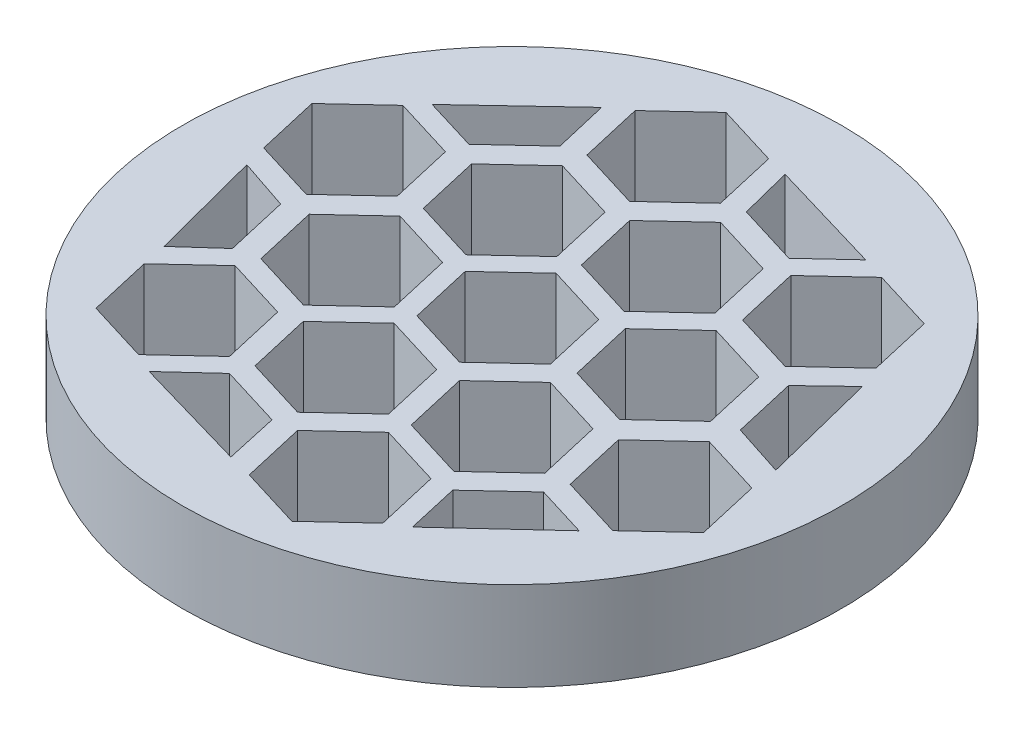
from build123d import *

# Parameters (mm, degrees)
SKIZZE1_R                       = 7.4
AUFSATZ_LINEAR_AUSTRAGEN2_DEPTH = 2
SCHNITT_LINEAR_AUSTRAGEN2_DEPTH = 2


with BuildPart() as part:
    # Skizze1 → Aufsatz-Linear austragen2 (new body)
    with BuildSketch(Plane(origin=(0, 0, 0), x_dir=(1, 0, 0), z_dir=(0, 1, 0))):
        Circle(SKIZZE1_R)
    extrude(amount=AUFSATZ_LINEAR_AUSTRAGEN2_DEPTH)

    # Skizze3 → Schnitt-Linear austragen2 (cut)
    with BuildSketch(Plane.XZ):
        Polygon((3.110355434, 1.292281092), (3.433750851, 2.698961133), (2.377227909, 3.6823698), (0.99730955, 3.259098426), (0.673914133, 1.852418385), (1.730437075, 0.869009718), align=None)
        Polygon((1.051482334, -0.894820995), (1.374877751, 0.511859046), (0.318354809, 1.495267713), (-1.06156355, 1.071996339), (-1.384958967, -0.334683702), (-0.328436025, -1.318092369), align=None)
        Polygon((3.962790655, -1.57756505), (4.286186071, -0.170885009), (3.229663129, 0.812523658), (1.84974477, 0.389252284), (1.526349354, -1.017427757), (2.582872296, -2.000836424), align=None)
        Polygon((1.908536497, -3.73106102), (2.231931914, -2.324380979), (1.175408972, -1.340972312), (-0.204509387, -1.764243686), (-0.527904804, -3.170923727), (0.528618138, -4.154332394), align=None)
        Polygon((-0.967115848, -3.0562984), (-0.643720431, -1.649618359), (-1.700243373, -0.666209692), (-3.080161732, -1.089481066), (-3.403557149, -2.496161107), (-2.347034207, -3.479569774), align=None)
        Polygon((-1.811929532, -0.253503523), (-1.488534116, 1.153176518), (-2.545057058, 2.136585185), (-3.924975416, 1.713313811), (-4.248370833, 0.30663377), (-3.191847891, -0.676774897), align=None)
        Polygon((0.205432908, 1.896097632), (0.528828325, 3.302777673), (-0.527694618, 4.28618634), (-1.907612976, 3.862914966), (-2.231008393, 2.456234925), (-1.174485451, 1.472826258), align=None)
        Polygon((6.04694768, 0.660967687), (6.370343097, 2.067647728), (5.313820155, 3.051056395), (3.933901796, 2.627785021), (3.610506379, 1.22110498), (4.667029321, 0.237696313), align=None)
        Polygon((4.786465264, -4.469572088), (5.109860681, -3.062892047), (4.053337739, -2.07948338), (2.67341938, -2.502754754), (2.350023963, -3.909434795), (3.406546905, -4.892843462), align=None)
        Polygon((-0.16753074, -5.930350774), (0.155864677, -4.523670733), (-0.900658265, -3.540262066), (-2.280576624, -3.96353344), (-2.603972041, -5.370213481), (-1.547449099, -6.353622148), align=None)
        Polygon((-3.933901796, -2.438733427), (-3.610506379, -1.032053386), (-4.667029321, -0.048644719), (-6.04694768, -0.471916093), (-6.370343097, -1.878596134), (-5.313820155, -2.862004801), align=None)
        Polygon((-2.700371821, 2.561167603), (-2.376976404, 3.967847644), (-3.433499346, 4.951256311), (-4.813417705, 4.527984937), (-5.136813122, 3.121304896), (-4.08029018, 2.137896229), align=None)
        Polygon((2.26230049, 4.081327536), (2.585695906, 5.488007577), (1.529172964, 6.471416244), (0.149254605, 6.04814487), (-0.174140811, 4.641464829), (0.882382131, 3.658056162), align=None)
        Polygon((4.939265844, 3.431140862), (2.995205508, 5.228874076), (2.728936611, 4.059318245), (3.785459554, 3.075909578), align=None)
        Polygon((5.313820155, -2.556040794), (5.967525742, 0.044561799), (4.788744949, -0.337862256), (4.465349532, -1.744542297), align=None)
        Polygon((0.318354809, -5.813813764), (2.887600861, -5.054112189), (1.995209721, -4.223766537), (0.615291362, -4.647037911), align=None)
        Polygon((-3.042477939, -5.054112189), (-2.757057663, -3.831247126), (-3.813580605, -2.847838459), (-5.002736834, -3.209095193), align=None)
        Polygon((-4.766685593, 0.428469167), (-4.443290177, 1.835149208), (-5.251077368, 2.561167603), (-5.909694674, 0.044561799), align=None)
        Polygon((-0.667764964, 4.720679563), (-0.406041453, 5.906533391), (-2.986939248, 5.160492623), (-2.047683323, 4.297408189), align=None)
    extrude(amount=-SCHNITT_LINEAR_AUSTRAGEN2_DEPTH, mode=Mode.SUBTRACT)


solid = part.part
